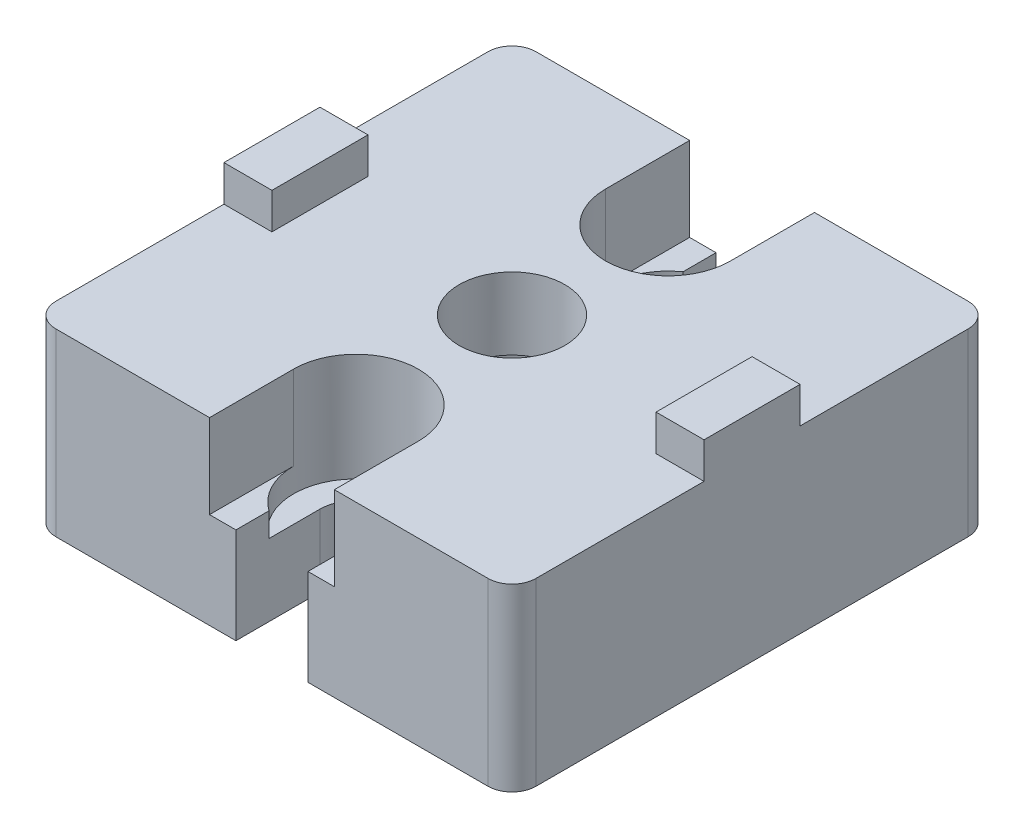
from build123d import *

# Parameters (mm, degrees)
SKETCH_1_W          = 40
SKETCH_1_H          = 40
EXTRUDE_1_DEPTH     = 15
SKETCH_2_W          = 4
SKETCH_2_H          = 8
EXTRUDE_2_DEPTH     = 3
SKETCH_3_R          = 4.4
CUT_EXTRUDE_1_DEPTH = 16
SKETCH_4_R          = 6.9
CUT_EXTRUDE_2_DEPTH = 9
CUT_EXTRUDE_3_DEPTH = 7
SKETCH_6_R          = 5.2
CUT_EXTRUDE_4_DEPTH = 2
FILLET_1_R          = 2


with BuildPart() as part:
    # Эскиз1 → Бобышка-Вытянуть1 (new body)
    with BuildSketch(Plane(origin=(0, 0, 0), x_dir=(1, 0, 0), z_dir=(0, 1, 0))):
        Rectangle(SKETCH_1_W, SKETCH_1_H)
    extrude(amount=EXTRUDE_1_DEPTH)

    # Эскиз2 → Бобышка-Вытянуть2 (add)
    with BuildSketch(Plane(origin=(0, 15, 0), x_dir=(1, 0, 0), z_dir=(0, 1, 0))):
        with Locations((-18, 0)):
            Rectangle(SKETCH_2_W, SKETCH_2_H)
        with Locations((18, 0)):
            Rectangle(SKETCH_2_W, SKETCH_2_H)
    extrude(amount=EXTRUDE_2_DEPTH)

    # Эскиз3 → Вырез-Вытянуть1 (cut, through all)
    with BuildSketch(Plane(origin=(0, 15, 0), x_dir=(1, 0, 0), z_dir=(0, 1, 0))):
        with Locations(Location((0, 0, 0), (0, 0, 270))):  # turned: the seam where the file's is
            Circle(SKETCH_3_R)
        with BuildLine():
            Line((-3, -20), (-3, -13))
            ThreePointArc((-3, -13), (0, -10), (3, -13))
            Line((3, -13), (3, -20))
            Line((3, -20), (-3, -20))
        make_face()
        with BuildLine():
            Line((3, 13), (3, 20))
            Line((3, 20), (-3, 20))
            Line((-3, 20), (-3, 13))
            ThreePointArc((-3, 13), (0, 10), (3, 13))
        make_face()
    extrude(amount=-CUT_EXTRUDE_1_DEPTH, mode=Mode.SUBTRACT)

    # Эскиз4 → Вырез-Вытянуть2 (cut)
    with BuildSketch(Plane.XZ):
        with Locations(Location((0, 0, 0), (0, 0, 270))):  # turned: the seam where the file's is
            Circle(SKETCH_4_R)
    extrude(amount=-CUT_EXTRUDE_2_DEPTH, mode=Mode.SUBTRACT)

    # Эскиз5 → Вырез-Вытянуть3 (cut)
    with BuildSketch(Plane(origin=(0, 15, 0), x_dir=(1, 0, 0), z_dir=(0, 1, 0))):
        with BuildLine():
            Line((-5.2, -20), (-5.2, -13))
            ThreePointArc((-5.2, -13), (0, -7.8), (5.2, -13))
            Line((5.2, -13), (5.2, -20))
            Line((5.2, -20), (-5.2, -20))
        make_face()
        with BuildLine():
            Line((5.2, 13), (5.2, 20))
            Line((5.2, 20), (-5.2, 20))
            Line((-5.2, 20), (-5.2, 13))
            ThreePointArc((-5.2, 13), (0, 7.8), (5.2, 13))
        make_face()
    extrude(amount=-CUT_EXTRUDE_3_DEPTH, mode=Mode.SUBTRACT)

    # Эскиз6 → Вырез-Вытянуть4 (cut)
    with BuildSketch(Plane(origin=(0, 8, 0), x_dir=(1, 0, 0), z_dir=(0, 1, 0))):
        with Locations((0, -13)):
            Circle(SKETCH_6_R)
        with Locations((0, 13)):
            Circle(SKETCH_6_R)
    extrude(amount=-CUT_EXTRUDE_4_DEPTH, mode=Mode.SUBTRACT)

    # Скругление1
    fillet_1_edges = [part.edges().sort_by_distance(p)[0] for p in [
        (-20, 7.5, -20),
        (20, 7.5, -20),
        (20, 7.5, 20),
        (-20, 7.5, 20),
    ]]
    fillet(fillet_1_edges, radius=FILLET_1_R)


solid = part.part
